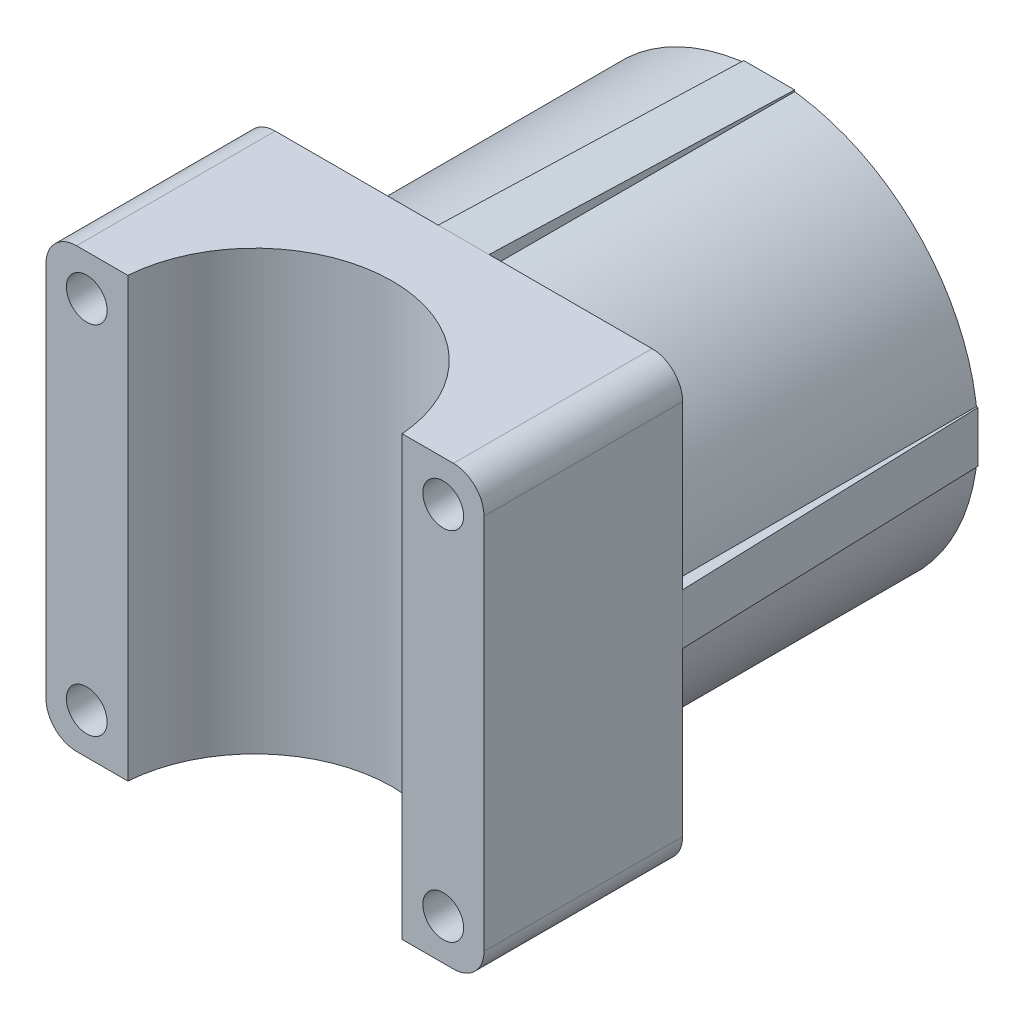
from build123d import *

# Parameters (mm, degrees)
CROQUIS1_W              = 43
CROQUIS1_H              = 43
SALIENTE_EXTRUIR1_DEPTH = 19.5
CROQUIS2_R              = 13.5
CORTAR_EXTRUIR1_DEPTH   = 44
CROQUIS3_R              = 2
CORTAR_EXTRUIR2_DEPTH   = 20.5
REDONDEO1_R             = 3
CROQUIS5_R              = 20.5
CROQUIS5_R_2            = 16.5
SALIENTE_EXTRUIR2_DEPTH = 30
EXTRUIR_L_MINA1_REACH   = 45.626
CROQUIS7_W              = 5
CROQUIS7_H              = 30.01666204
EXTRUIR_L_MINA2_REACH   = 45.626
CROQUIS8_W              = 30.01666204
CROQUIS8_H              = 5
EXTRUIR_L_MINA3_REACH   = 45.626
CROQUIS9_W              = 5
CROQUIS9_H              = 30.016662039
EXTRUIR_L_MINA4_REACH   = 45.626
CROQUIS10_W             = 30.016662039
CROQUIS10_H             = 5


with BuildPart() as part:
    # Croquis1 → Saliente-Extruir1 (new body)
    with BuildSketch(Plane.XY):
        with Locations((-58.504320503, 22.141791045)):
            Rectangle(CROQUIS1_W, CROQUIS1_H)
    extrude(amount=SALIENTE_EXTRUIR1_DEPTH)

    # Croquis2 → Cortar-Extruir1 (cut, through all)
    with BuildSketch(Plane(origin=(0, 43.641791045, 0), x_dir=(1, 0, 0), z_dir=(0, 1, 0))):
        with Locations((-58.504320503, -20.5)):
            Circle(CROQUIS2_R)
    extrude(amount=-CORTAR_EXTRUIR1_DEPTH, mode=Mode.SUBTRACT)

    # Croquis3 → Cortar-Extruir2 (cut, through all)
    with BuildSketch(Plane.XY.offset(19.5)):
        with Locations((-76.004320503, 39.641791045)):
            Circle(CROQUIS3_R)
        with Locations((-41.004320503, 39.641791045)):
            Circle(CROQUIS3_R)
        with Locations((-41.004320503, 4.641791045)):
            Circle(CROQUIS3_R)
        with Locations((-76.004320503, 4.641791045)):
            Circle(CROQUIS3_R)
    extrude(amount=-CORTAR_EXTRUIR2_DEPTH, mode=Mode.SUBTRACT)

    # Redondeo1
    redondeo1_edges = [part.edges().sort_by_distance(p)[0] for p in [
        (-80.004320503, 43.641791045, 9.75),
        (-37.004320503, 43.641791045, 9.75),
        (-37.004320503, 0.641791045, 9.75),
        (-80.004320503, 0.641791045, 9.75),
    ]]
    fillet(redondeo1_edges, radius=REDONDEO1_R)

    # Croquis5 → Saliente-Extruir2 (add)
    with BuildSketch(Plane(origin=(0, 0, 0), x_dir=(-1, 0, 0), z_dir=(0, 0, -1))):
        with Locations((58.504320503, 22.141791045)):
            Circle(CROQUIS5_R)
        with Locations((58.504320503, 22.141791045)):
            Circle(CROQUIS5_R_2, mode=Mode.SUBTRACT)
    extrude(amount=SALIENTE_EXTRUIR2_DEPTH)

    # Croquis7 → Extruir-Lámina1 (add, up to next)
    with BuildSketch(Plane(origin=(0, 43.593353985, -1.453111799), x_dir=(-1, 0, 0), z_dir=(0, -0.999444907, 0.03331483)), mode=Mode.PRIVATE) as extruir_l_mina1_sk1:
        with Locations((58.504320503, 13.55441216)):
            Rectangle(CROQUIS7_W, CROQUIS7_H)
    extruir_l_mina1_tool1 = extrude(extruir_l_mina1_sk1.sketch, amount=EXTRUIR_L_MINA1_REACH, mode=Mode.PRIVATE) - part.part
    add(extruir_l_mina1_tool1.solids().sort_by_distance((-58.504321, 43.141791, -15))[0])

    # Croquis8 → Extruir-Lámina2 (add, up to next)
    with BuildSketch(Plane(origin=(-36.963250225, 0, 1.232108341), x_dir=(0.03331483, 0, 0.999444907), z_dir=(-0.999444907, 0, 0.03331483)), mode=Mode.PRIVATE) as extruir_l_mina2_sk1:
        with Locations((-16.241123675, 22.141791045)):
            Rectangle(CROQUIS8_W, CROQUIS8_H)
    extruir_l_mina2_tool1 = extrude(extruir_l_mina2_sk1.sketch, amount=EXTRUIR_L_MINA2_REACH, mode=Mode.PRIVATE) - part.part
    add(extruir_l_mina2_tool1.solids().sort_by_distance((-37.504321, 22.141791, -15))[0])

    # Croquis9 → Extruir-Lámina3 (add, up to next)
    with BuildSketch(Plane(origin=(0, 0.641078735, 0.021369291), x_dir=(1, 0, 0), z_dir=(0, 0.999444907, 0.03331483)), mode=Mode.PRIVATE) as extruir_l_mina3_sk1:
        with Locations((-58.504320503, 15.02971218)):
            Rectangle(CROQUIS9_W, CROQUIS9_H)
    extruir_l_mina3_tool1 = extrude(extruir_l_mina3_sk1.sketch, amount=EXTRUIR_L_MINA3_REACH, mode=Mode.PRIVATE) - part.part
    add(extruir_l_mina3_tool1.solids().sort_by_distance((-58.504321, 1.141791, -15))[0])

    # Croquis10 → Extruir-Lámina4 (add, up to next)
    with BuildSketch(Plane(origin=(-79.915525474, 0, -2.663850849), x_dir=(0.03331483, 0, -0.999444907), z_dir=(0.999444907, 0, 0.03331483)), mode=Mode.PRIVATE) as extruir_l_mina4_sk1:
        with Locations((12.343000664, 22.141791045)):
            Rectangle(CROQUIS10_W, CROQUIS10_H)
    extruir_l_mina4_tool1 = extrude(extruir_l_mina4_sk1.sketch, amount=EXTRUIR_L_MINA4_REACH, mode=Mode.PRIVATE) - part.part
    add(extruir_l_mina4_tool1.solids().sort_by_distance((-79.504321, 22.141791, -15))[0])


solid = part.part
